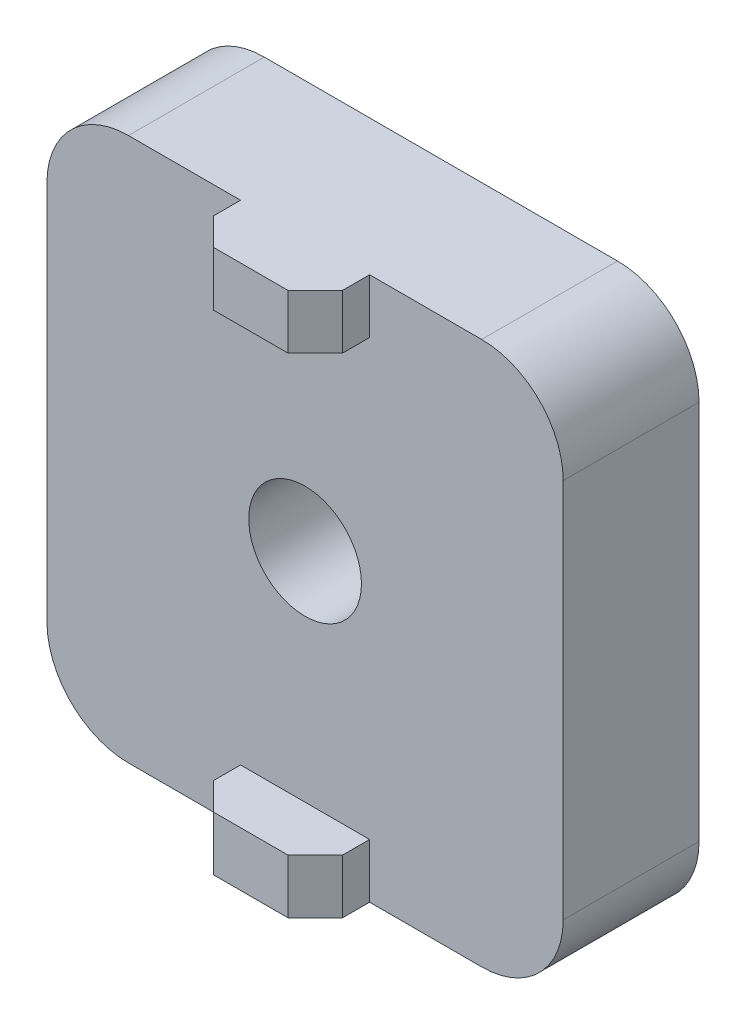
from build123d import *

# Parameters (mm, degrees)
SKETCH1_W           = 38
SKETCH1_H           = 40
SKETCH1_R           = 4.15
BOSS_EXTRUDE1_DEPTH = 5
FILLET1_R           = 6
SKETCH2_W           = 9.5
SKETCH2_H           = 4
BOSS_EXTRUDE2_DEPTH = 4
CHAMFER1_SIZE       = 2


with BuildPart() as part:
    # Sketch1 → Boss-Extrude1 (new body, symmetric)
    with BuildSketch(Plane.XY):
        Rectangle(SKETCH1_W, SKETCH1_H)
        Circle(SKETCH1_R, mode=Mode.SUBTRACT)
    extrude(amount=BOSS_EXTRUDE1_DEPTH, both=True)

    # Fillet1
    fillet1_edges = [part.edges().sort_by_distance(p)[0] for p in [
        (19, -20, 0),
        (-19, -20, 0),
        (-19, 20, 0),
        (19, 20, 0),
    ]]
    fillet(fillet1_edges, radius=FILLET1_R)

    # Sketch2 → Boss-Extrude2 (add)
    with BuildSketch(Plane.XY.offset(5)):
        with Locations((0, 18)):
            Rectangle(SKETCH2_W, SKETCH2_H)
        with Locations((0, -18)):
            Rectangle(SKETCH2_W, SKETCH2_H)
    extrude(amount=BOSS_EXTRUDE2_DEPTH)

    # Chamfer1
    chamfer1_edges = [part.edges().sort_by_distance(p)[0] for p in [
        (4.75, 18, 9),
        (-4.75, 18, 9),
        (-4.75, -18, 9),
        (4.75, -18, 9),
    ]]
    chamfer(chamfer1_edges, length=CHAMFER1_SIZE)


solid = part.part
